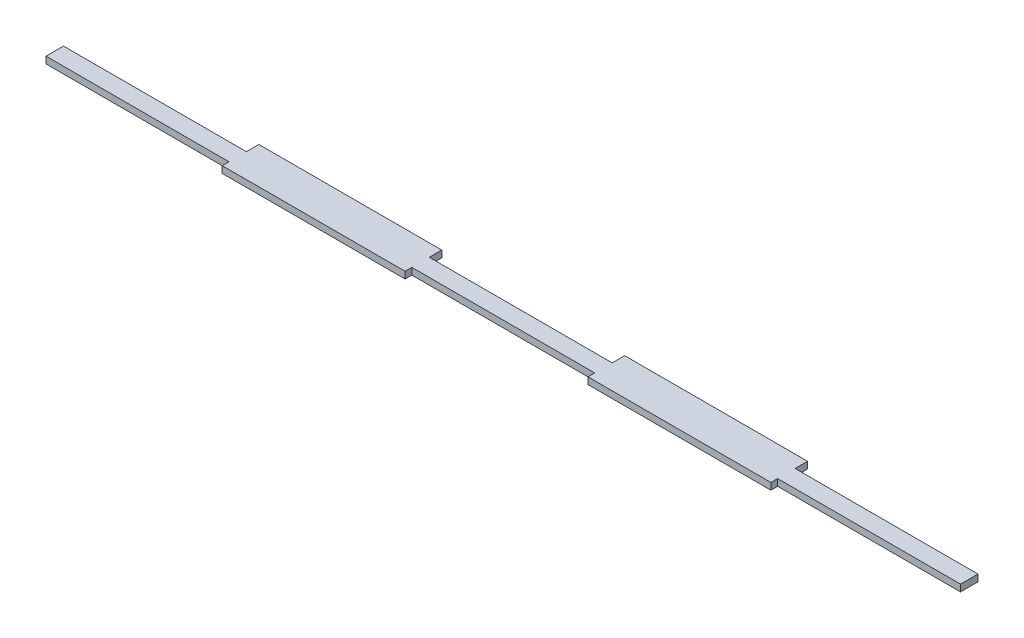
from build123d import *

# Parameters (mm, degrees)
BOSS_EXTRUDE1_DEPTH = 2.7


with BuildPart() as part:
    # Sketch1 → Boss-Extrude1 (new body)
    with BuildSketch(Plane(origin=(0, 0, 0), x_dir=(1, 0, 0), z_dir=(0, 1, 0))):
        Polygon((-183.2, 4.329370209), (-109.92, 4.329370209), (-109.92, 9.329370209), (-36.64, 9.329370209), (-36.64, 4.329370209), (36.64, 4.329370209), (36.64, 9.329370209), (109.92, 9.329370209), (109.92, 4.329370209), (183.2, 4.329370209), (183.2, -2.670629791), (109.92, -2.670629791), (109.92, -5.370629791), (36.64, -5.370629791), (36.64, -2.670629791), (-36.64, -2.670629791), (-36.64, -5.370629791), (-109.92, -5.370629791), (-109.92, -2.670629791), (-183.2, -2.670629791), align=None)
    extrude(amount=BOSS_EXTRUDE1_DEPTH)


solid = part.part
